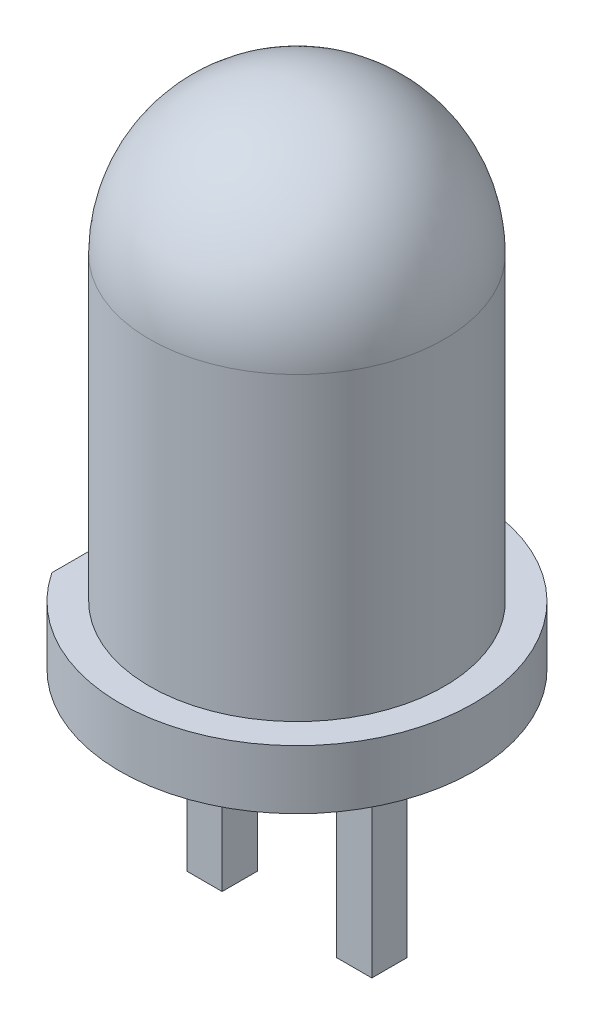
from build123d import *

# Parameters (mm, degrees)
ESQUISSE2_W             = 0.6
ESQUISSE2_H             = 0.6
BOSS_EXTRU_1_DEPTH      = 3.6
ESQUISSE3_W             = 1
ESQUISSE3_H             = 4
ENL_V_MAT_EXTRU_1_DEPTH = 9.6


with BuildPart() as part:
    # Esquisse1 → Révolution1 (revolve)
    with BuildSketch(Plane.XY):
        with BuildLine():
            Line((0, 0), (-3, 0))
            Line((-3, 0), (-3, 1))
            Line((-3, 1), (-2.5, 1))
            Line((-2.5, 1), (-2.5, 6.1))
            ThreePointArc((-2.5, 6.1), (-1.767766953, 7.867766953), (0, 8.6))
            Line((0, 8.6), (0, 0))
        make_face()
    revolve(axis=Axis((0, 8.6, 0), (0, -1, 0)))

    # Esquisse2 → Boss.-Extru.1 (add)
    with BuildSketch(Plane.XZ):
        with Locations((-1.27, 0)):
            Rectangle(ESQUISSE2_W, ESQUISSE2_H)
        with Locations((1.27, 0)):
            Rectangle(ESQUISSE2_W, ESQUISSE2_H)
    extrude(amount=BOSS_EXTRU_1_DEPTH)

    # Esquisse3 → Enlèv. mat.-Extru.1 (cut, through all)
    with BuildSketch(Plane.XZ):
        with Locations((-3, 0)):
            Rectangle(ESQUISSE3_W, ESQUISSE3_H)
    extrude(amount=-ENL_V_MAT_EXTRU_1_DEPTH, mode=Mode.SUBTRACT)


solid = part.part
